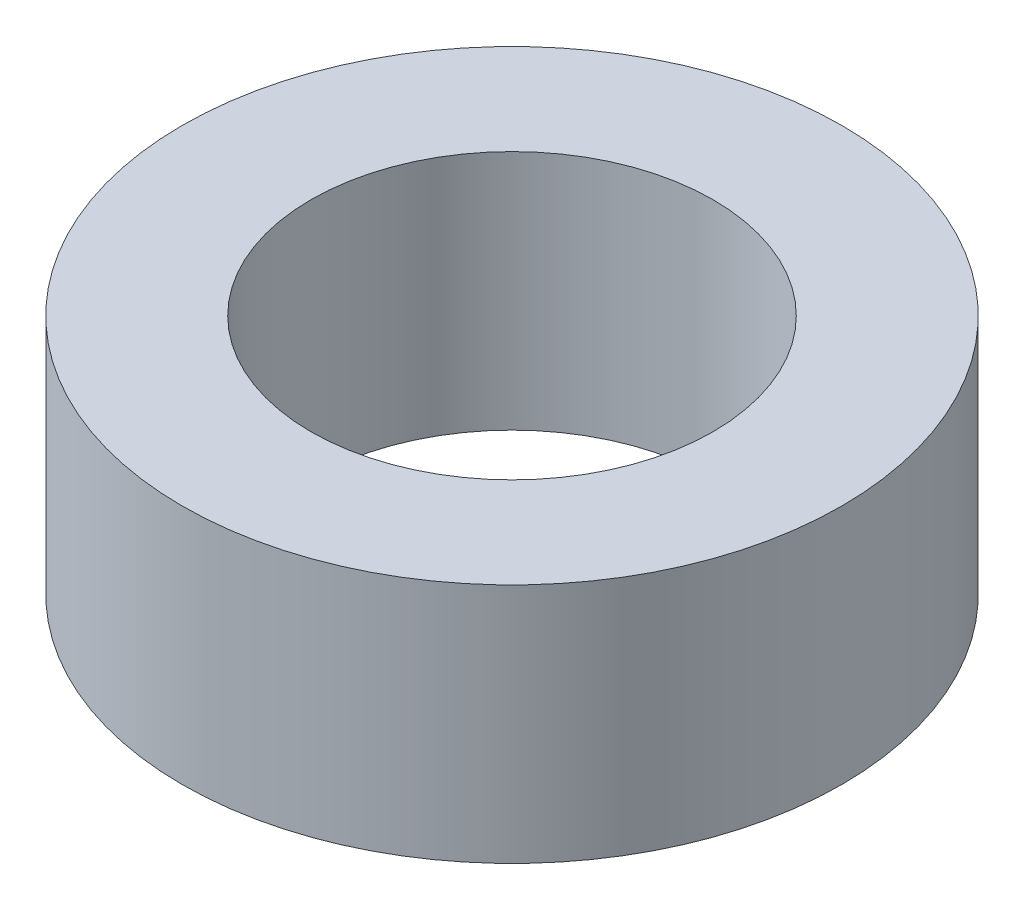
from build123d import *

# Parameters (mm, degrees)
CROQUIS1_R              = 20.5
CROQUIS1_R_2            = 12.5
SALIENTE_EXTRUIR1_DEPTH = 15


with BuildPart() as part:
    # Croquis1 → Saliente-Extruir1 (new body)
    with BuildSketch(Plane(origin=(0, 0, 0), x_dir=(1, 0, 0), z_dir=(0, 1, 0))):
        Circle(CROQUIS1_R)
        Circle(CROQUIS1_R_2, mode=Mode.SUBTRACT)
    extrude(amount=SALIENTE_EXTRUIR1_DEPTH)


solid = part.part
